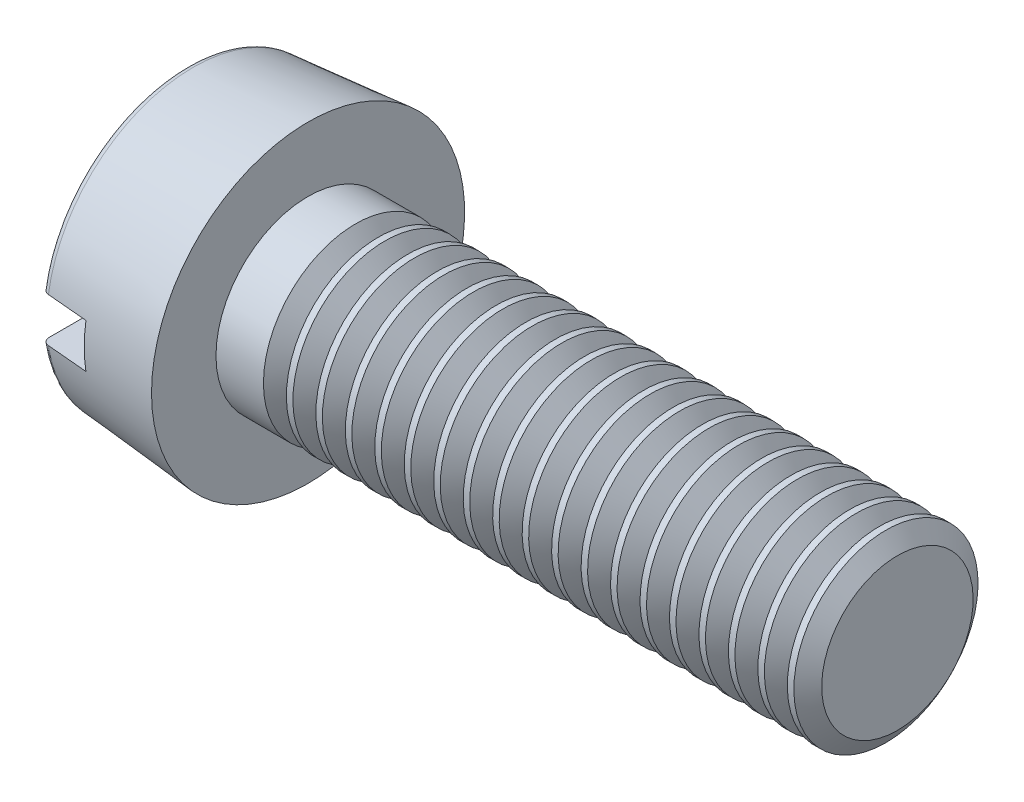
from build123d import *

# Parameters (mm, degrees)
FILLET2_R       = 0.2
SKETCH2_W       = 8.5
SKETCH2_H       = 1.2
SLOT_DEPTH      = 1.3
THDSCHPAT_COUNT = 19
THDSCHPAT_PITCH = 0.8


with BuildPart() as part:
    # BodySke → Base-Revolve (revolve)
    with BuildSketch(Plane.XY):
        Polygon((3.3, 2.5), (3.3, 4.25), (0, 3.96128741), (0, 0), (19.3, 0), (19.3, 2.5), align=None)
    revolve(axis=Axis((-25.4, 0, 0), (1, 0, 0)))

    # Fillet2
    fillet2_edges = [part.edges().sort_by_distance(p)[0] for p in [
        (0, -3.96128741, 0),
    ]]
    fillet(fillet2_edges, radius=FILLET2_R)

    # Sketch2 → Slot (cut)
    with BuildSketch(Plane(origin=(0, 0, 0), x_dir=(0, 0, -1), z_dir=(1, 0, 0))):
        Rectangle(SKETCH2_W, SKETCH2_H)
    extrude(amount=SLOT_DEPTH, mode=Mode.SUBTRACT)

    # ThdSchSke → ThreadSchematic (revolve, cut)
    with BuildSketch(Plane.XY):
        Polygon((4.9, -2.055), (4.588407645, -2.5), (4.588407645, -3.125), (5.211592355, -3.125), (5.211592355, -2.5), align=None)
    threadschematic = revolve(axis=Axis((-3.175, 0, 0), (1, 0, 0)), mode=Mode.SUBTRACT)

    # ThdSchPat: ThreadSchematic ×19
    with Locations(*[(i * THDSCHPAT_PITCH, 0, 0) for i in range(1, THDSCHPAT_COUNT)]):
        add(threadschematic, mode=Mode.SUBTRACT)


solid = part.part
